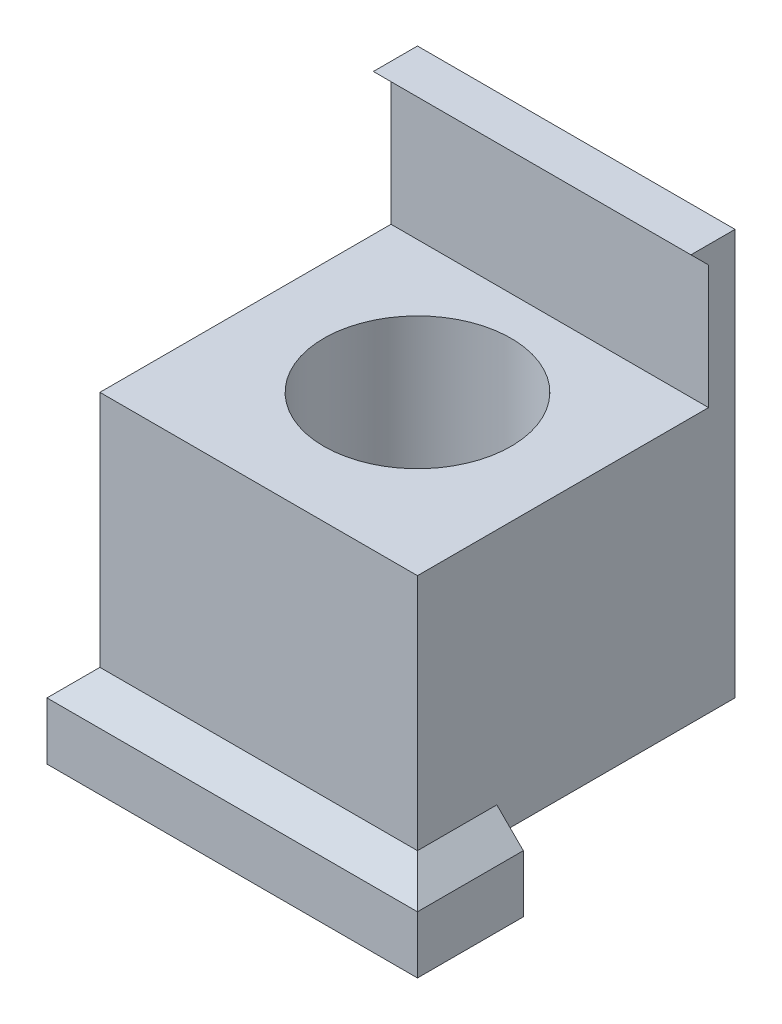
from build123d import *

# Parameters (mm, degrees)
SKETCH1_W            = 18
SKETCH1_H            = 18
BOSS_EXTRUDE1_DEPTH  = 15
SKETCH3_R            = 5.306691295
CUT_EXTRUDE1_DEPTH   = 11.5
SKETCH4_W            = 18
SKETCH4_H            = 1.5
BOSS_EXTRUDE2_DEPTH  = 8
SKETCH6_W            = 18
SKETCH6_H            = 0.997263539
BOSS_EXTRUDE3_DEPTH  = 1
CUT_EXTRUDE2_DEPTH   = 18
SKETCH9_W            = 18
SKETCH9_H            = 1.5
BOSS_EXTRUDE4_DEPTH  = 1.5
SKETCH10_W           = 18
SKETCH10_H           = 1.5
BOSS_EXTRUDE6_DEPTH  = 3.25
SKETCH11_W           = 18
SKETCH11_H           = 1.625
BOSS_EXTRUDE7_DEPTH  = 1.5
SKETCH13_W           = 19.5
SKETCH13_H           = 1.5
BOSS_EXTRUDE9_DEPTH  = 1.5
SKETCH14_W           = 1.5
SKETCH14_H           = 19.5
BOSS_EXTRUDE10_DEPTH = 3.25
SKETCH15_W           = 19.5
SKETCH15_H           = 1.756529455
BOSS_EXTRUDE11_DEPTH = 1.5
SKETCH16_W           = 6
SKETCH16_H           = 1.5
BOSS_EXTRUDE12_DEPTH = 1.5
SKETCH17_W           = 1.5
SKETCH17_H           = 6
BOSS_EXTRUDE13_DEPTH = 3.25
SKETCH18_W           = 3
SKETCH18_H           = 1.625
BOSS_EXTRUDE14_DEPTH = 1.5
CUT_EXTRUDE3_DEPTH   = 18
CUT_EXTRUDE11_DEPTH  = 21
CUT_EXTRUDE12_DEPTH  = 2
CUT_EXTRUDE13_DEPTH  = 2


with BuildPart() as part:
    # Sketch1 → Boss-Extrude1 (new body)
    with BuildSketch(Plane(origin=(0, 0, 0), x_dir=(1, 0, 0), z_dir=(0, 1, 0))):
        with Locations((-5.757576823, 3.532227937)):
            Rectangle(SKETCH1_W, SKETCH1_H)
    extrude(amount=BOSS_EXTRUDE1_DEPTH)

    # Sketch3 → Cut-Extrude1 (cut)
    with BuildSketch(Plane(origin=(0, 15, 0), x_dir=(1, 0, 0), z_dir=(0, 1, 0))):
        with Locations((-5.757576823, 3.532227937)):
            Circle(SKETCH3_R)
    extrude(amount=-CUT_EXTRUDE1_DEPTH, mode=Mode.SUBTRACT)

    # Sketch4 → Boss-Extrude2 (add)
    with BuildSketch(Plane(origin=(0, 15, 0), x_dir=(1, 0, 0), z_dir=(0, 1, 0))):
        with Locations((-5.757576823, 11.782227937)):
            Rectangle(SKETCH4_W, SKETCH4_H)
    extrude(amount=BOSS_EXTRUDE2_DEPTH)

    # Sketch6 → Boss-Extrude3 (add)
    with BuildSketch(Plane.XY.offset(-11.032227937)):
        with Locations((-5.757576823, 22.50136823)):
            Rectangle(SKETCH6_W, SKETCH6_H)
    extrude(amount=BOSS_EXTRUDE3_DEPTH)

    # Sketch7 → Cut-Extrude2 (cut)
    with BuildSketch(Plane.ZY.offset(14.757576823)):
        Polygon((-11.032227937, 22.002736461), (-10.032227937, 23), (-10.032227937, 22.002736461), align=None)
    extrude(amount=-CUT_EXTRUDE2_DEPTH, mode=Mode.SUBTRACT)

    # Sketch9 → Boss-Extrude4 (add)
    with BuildSketch(Plane.XY.offset(5.467772063)):
        with Locations((-5.757576823, 0.75)):
            Rectangle(SKETCH9_W, SKETCH9_H)
    extrude(amount=BOSS_EXTRUDE4_DEPTH)

    # Sketch10 → Boss-Extrude6 (add)
    with BuildSketch(Plane.XZ):
        with Locations((-5.757576823, 6.217772063)):
            Rectangle(SKETCH10_W, SKETCH10_H)
    extrude(amount=BOSS_EXTRUDE6_DEPTH)

    # Sketch11 → Boss-Extrude7 (add)
    with BuildSketch(Plane(origin=(0, 0, 5.467772063), x_dir=(-1, 0, 0), z_dir=(0, 0, -1))):
        with Locations((5.757576823, -2.4375)):
            Rectangle(SKETCH11_W, SKETCH11_H)
    extrude(amount=BOSS_EXTRUDE7_DEPTH)

    # Sketch13 → Boss-Extrude9 (add)
    with BuildSketch(Plane.ZY.offset(14.757576823)):
        with Locations((-2.782227937, 0.75)):
            Rectangle(SKETCH13_W, SKETCH13_H)
    extrude(amount=BOSS_EXTRUDE9_DEPTH)

    # Sketch14 → Boss-Extrude10 (add)
    with BuildSketch(Plane.XZ):
        with Locations((-15.507576823, -2.782227937)):
            Rectangle(SKETCH14_W, SKETCH14_H)
    extrude(amount=BOSS_EXTRUDE10_DEPTH)

    # Sketch15 → Boss-Extrude11 (add)
    with BuildSketch(Plane(origin=(-14.757576823, 0, 0), x_dir=(0, 0, -1), z_dir=(1, 0, 0))):
        with Locations((2.782227937, -2.371735273)):
            Rectangle(SKETCH15_W, SKETCH15_H)
    extrude(amount=BOSS_EXTRUDE11_DEPTH)

    # Sketch16 → Boss-Extrude12 (add)
    with BuildSketch(Plane(origin=(3.242423177, 0, 0), x_dir=(0, 0, -1), z_dir=(1, 0, 0))):
        with Locations((-3.967772063, 0.75)):
            Rectangle(SKETCH16_W, SKETCH16_H)
    extrude(amount=BOSS_EXTRUDE12_DEPTH)

    # Sketch17 → Boss-Extrude13 (add)
    with BuildSketch(Plane.XZ):
        with Locations((3.992423177, 3.967772063)):
            Rectangle(SKETCH17_W, SKETCH17_H)
    extrude(amount=BOSS_EXTRUDE13_DEPTH)

    # Sketch18 → Boss-Extrude14 (add)
    with BuildSketch(Plane.ZY.offset(-3.242423177)):
        with Locations((2.467772063, -2.4375)):
            Rectangle(SKETCH18_W, SKETCH18_H)
    extrude(amount=BOSS_EXTRUDE14_DEPTH)

    # Sketch19 → Cut-Extrude3 (cut)
    with BuildSketch(Plane(origin=(0, 0, -12.532227937), x_dir=(-1, 0, 0), z_dir=(0, 0, -1))):
        Polygon((16.257576823, 0), (14.757576823, 1.5), (16.257576823, 1.5), align=None)
        Polygon((-4.742423177, 0), (-3.242423177, 1.5), (-4.742423177, 1.5), align=None)
    extrude(amount=-CUT_EXTRUDE3_DEPTH, mode=Mode.SUBTRACT)

    # Sketch22 → Cut-Extrude11 (cut)
    with BuildSketch(Plane(origin=(4.742423177, 0, 0), x_dir=(0, 0, -1), z_dir=(1, 0, 0))):
        Polygon((-6.967772063, 0), (-6.967772063, 1.5), (-5.467772063, 1.5), align=None)
    extrude(amount=-CUT_EXTRUDE11_DEPTH, mode=Mode.SUBTRACT)

    # Sketch24 → Cut-Extrude12 (cut)
    with BuildSketch(Plane(origin=(0, 0, 5.467772063), x_dir=(-1, 0, 0), z_dir=(0, 0, -1))):
        Polygon((-3.242423177, 1.5), (-4.742423177, 0), (-4.742423177, 1.5), align=None)
    extrude(amount=-CUT_EXTRUDE12_DEPTH, mode=Mode.SUBTRACT)

    # Sketch25 → Cut-Extrude13 (cut)
    with BuildSketch(Plane(origin=(0, 0, 5.467772063), x_dir=(-1, 0, 0), z_dir=(0, 0, -1))):
        Polygon((16.257576823, 0), (14.757576823, 1.5), (16.257576823, 1.5), align=None)
    extrude(amount=-CUT_EXTRUDE13_DEPTH, mode=Mode.SUBTRACT)


solid = part.part
